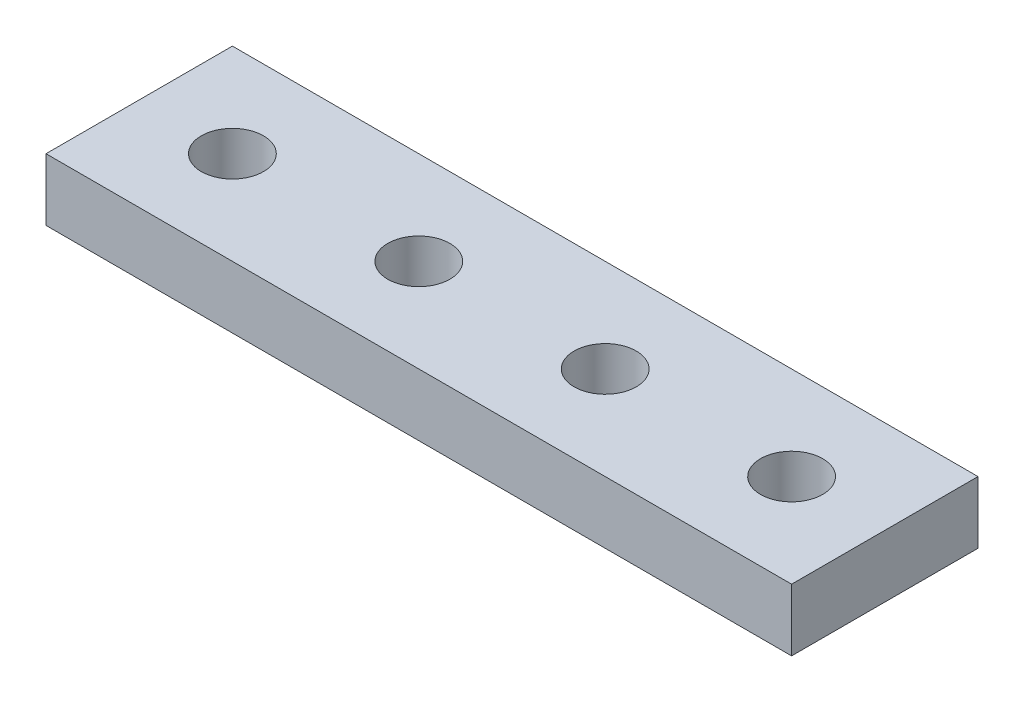
from build123d import *

# Parameters (mm, degrees)
SKETCH1_W           = 120
SKETCH1_H           = 30
BOSS_EXTRUDE1_DEPTH = 10
SKETCH3_R           = 5
CUT_EXTRUDE1_DEPTH  = 11


with BuildPart() as part:
    # Sketch1 → Boss-Extrude1 (new body)
    with BuildSketch(Plane(origin=(0, 0, 0), x_dir=(1, 0, 0), z_dir=(0, 1, 0))):
        Rectangle(SKETCH1_W, SKETCH1_H)
    extrude(amount=BOSS_EXTRUDE1_DEPTH)

    # Sketch3 → Cut-Extrude1 (cut, through all)
    with BuildSketch(Plane(origin=(0, 10, 0), x_dir=(1, 0, 0), z_dir=(0, 1, 0))):
        with Locations((-45, 0)):
            Circle(SKETCH3_R)
        with Locations((-15, 0)):
            Circle(SKETCH3_R)
        with Locations((15, 0)):
            Circle(SKETCH3_R)
        with Locations((45, 0)):
            Circle(SKETCH3_R)
    extrude(amount=-CUT_EXTRUDE1_DEPTH, mode=Mode.SUBTRACT)


solid = part.part
